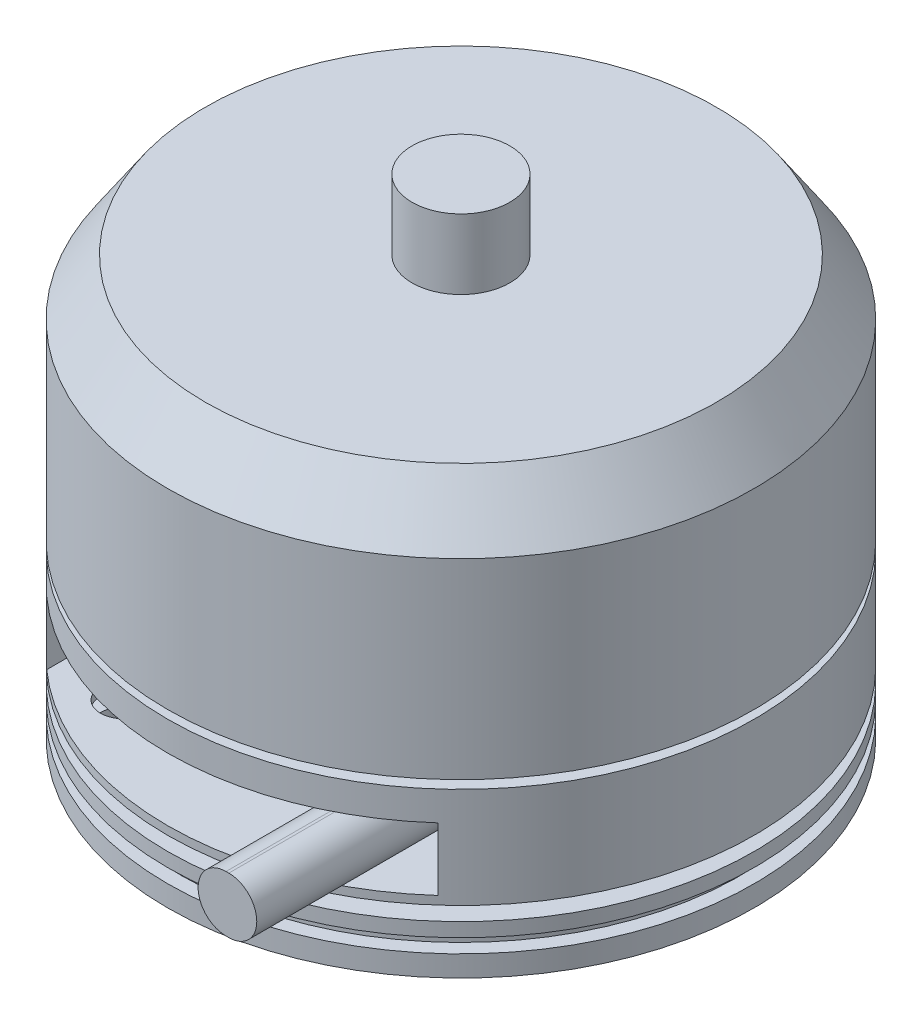
from build123d import *

# Parameters (mm, degrees)
SKETCH_2_W             = 28
SKETCH_2_H             = 4.5
CUT_EXTRUDE_1_DEPTH    = 10
EXTRUDE_1_DEPTH        = 15
HOLE_WIZARD_M4_2_D     = 3.3
HOLE_WIZARD_M4_2_DEPTH = 10.5
HOLE_WIZARD_M4_2_TIP   = 0.991420021


with BuildPart() as part:
    # 草图1 → 旋转1 (revolve)
    with BuildSketch(Plane.XY):
        Polygon((0, 0), (4.1, 0), (4.1, 6.7), (13.4, 6.7), (13.4, 8.7), (21, 8.7), (21, 10.2), (20, 10.2), (20, 11.2), (21, 11.2), (21, 12.2), (10, 12.2), (10, 13.2), (21, 13.2), (21, 20.4), (5, 20.4), (5, 21), (21, 21), (21, 34.7), (18.3, 38.7), (3.5, 38.7), (3.5, 43.7), (0, 43.7), align=None)
    revolve(axis=Axis((0, 43.7, 0), (0, -1, 0)))

    # 草图2 → 切除-拉伸1 (cut)
    with BuildSketch(Plane.XY.offset(21)):
        with Locations((0, 16.05)):
            Rectangle(SKETCH_2_W, SKETCH_2_H)
    extrude(amount=-CUT_EXTRUDE_1_DEPTH, mode=Mode.SUBTRACT)

    # 草图3 → 凸台-拉伸1 (add)
    with BuildSketch(Plane.XY.offset(11)):
        with BuildLine():
            Line((9.185056323, 18.053194417), (9.385056323, 18.053194417))
            ThreePointArc((9.385056323, 18.053194417), (11.385056323, 16.053194417), (9.385056323, 14.053194417))
            Line((9.385056323, 14.053194417), (9.185056323, 14.053194417))
            ThreePointArc((9.185056323, 14.053194417), (7.185056323, 16.053194417), (9.185056323, 18.053194417))
        make_face()
    extrude(amount=EXTRUDE_1_DEPTH)

    # M4 螺纹孔2
    with Locations(Plane(origin=(-14.780985523, 8.7, -9.368696119), x_dir=(0, 0, -1), z_dir=(0, -1, 0))):
        with Locations((0, 0), (-24.149681642, 5.412289404), (5.412289404, 24.149681642), (-18.737392238, 29.561971046)):
            Hole(HOLE_WIZARD_M4_2_D / 2, depth=HOLE_WIZARD_M4_2_DEPTH)
            with Locations((0, 0, -(HOLE_WIZARD_M4_2_DEPTH + HOLE_WIZARD_M4_2_TIP / 2))):  # 118° drill point
                Cone(0, HOLE_WIZARD_M4_2_D / 2, HOLE_WIZARD_M4_2_TIP, mode=Mode.SUBTRACT)


solid = part.part
